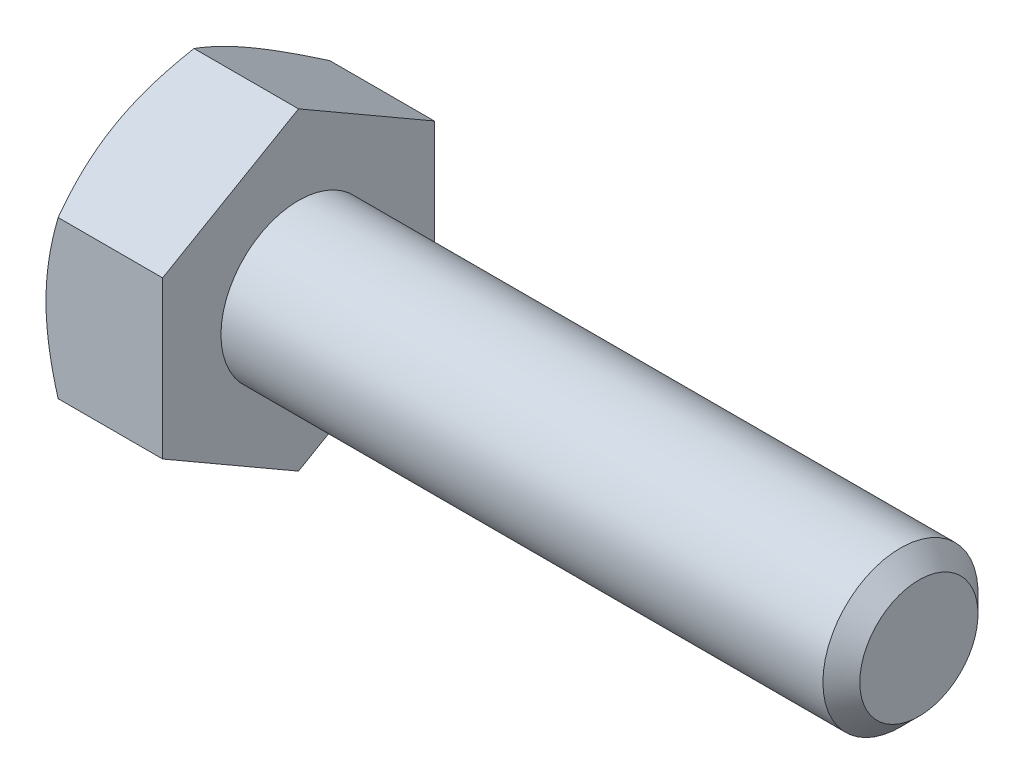
from build123d import *

# Parameters (mm, degrees)
BASEHEAD_DEPTH = 4.7752


with BuildPart() as part:
    # Sketch1 → BaseHead (new body)
    with BuildSketch(Plane(origin=(0, 0, 0), x_dir=(0, 0, -1), z_dir=(1, 0, 0))):
        Polygon((5.5626, 3.211568607), (5.5626, -3.211568607), (0, -6.423137215), (-5.5626, -3.211568607), (-5.5626, 3.211568607), (0, 6.423137215), align=None)
    extrude(amount=BASEHEAD_DEPTH)

    # BodySke → BaseBody (revolve)
    with BuildSketch(Plane.XY):
        Polygon((0, 0), (30.1752, 0), (30.1752, 2.41935), (29.41955, 3.175), (0, 3.175), align=None)
    revolve(axis=Axis((0, 0, 0), (1, 0, 0)))

    # Sketch3 → HeadChamfer (revolve, cut)
    with BuildSketch(Plane.XY):
        Polygon((0, 5.5626), (4.163005602, 12.773137215), (4.163005602, 19.123137215), (-12.7, 19.123137215), (-12.7, 5.5626), align=None)
    revolve(axis=Axis((0, 0, 0), (1, 0, 0)), mode=Mode.SUBTRACT)


solid = part.part
